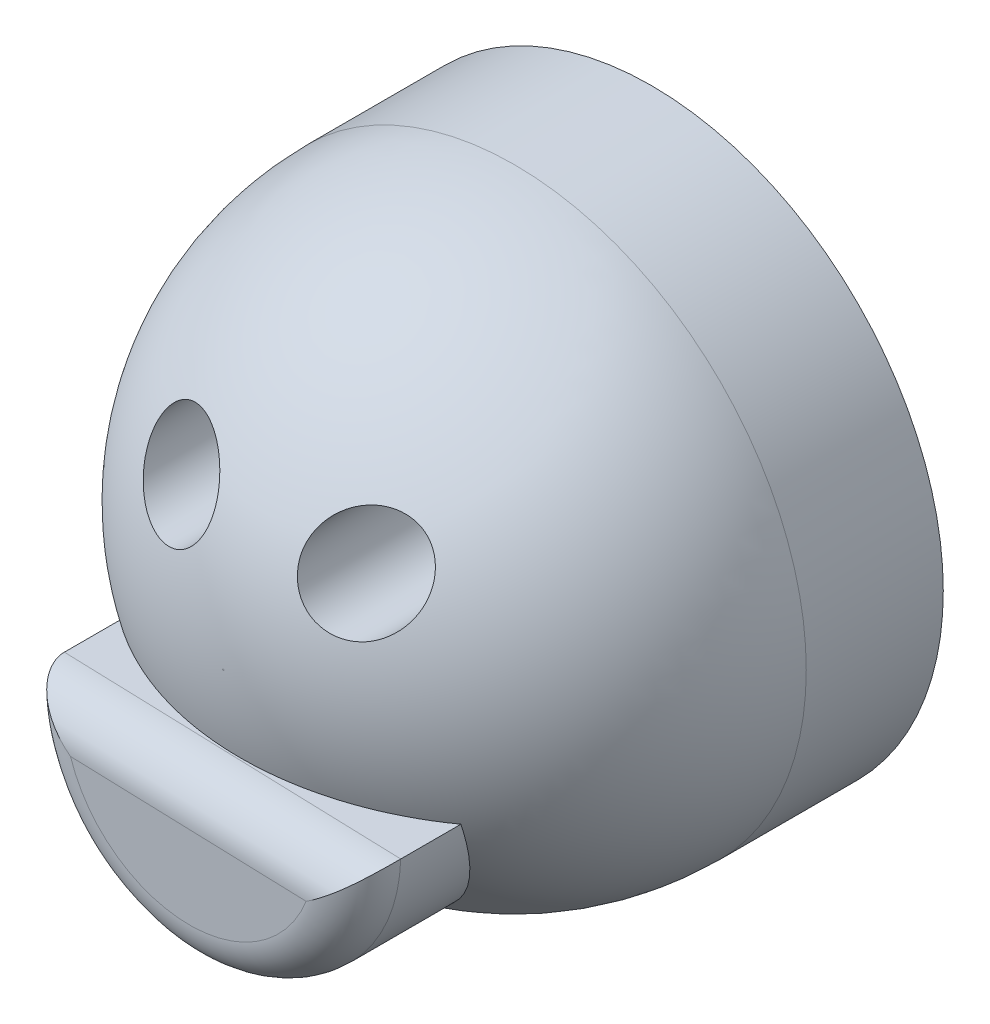
from build123d import *

# Parameters (mm, degrees)
SKETCH1_R           = 34.075
BOSS_EXTRUDE1_DEPTH = 50
FILLET1_R           = 34
SKETCH3_R           = 5.5
CUT_EXTRUDE1_DEPTH  = 57
BOSS_EXTRUDE2_DEPTH = 54
FILLET2_R           = 5
SKETCH5_R           = 28.2539
CUT_EXTRUDE2_DEPTH  = 27


with BuildPart() as part:
    # Sketch1 → Boss-Extrude1 (new body)
    with BuildSketch(Plane.XY):
        Circle(SKETCH1_R)
    extrude(amount=BOSS_EXTRUDE1_DEPTH)

    # Fillet1
    fillet1_edges = [part.edges().sort_by_distance(p)[0] for p in [
        (-34.075, 0, 50),
    ]]
    fillet(fillet1_edges, radius=FILLET1_R)

    # Sketch3 → Cut-Extrude1 (cut)
    with BuildSketch(Plane(origin=(0, 0, 0), x_dir=(-1, 0, 0), z_dir=(0, 0, -1))):
        with Locations((-11.427232, 12.850521)):
            Circle(SKETCH3_R)
        with Locations((9.257377, 12.850521)):
            Circle(SKETCH3_R)
    extrude(amount=-CUT_EXTRUDE1_DEPTH, mode=Mode.SUBTRACT)

    # Sketch4 → Boss-Extrude2 (add)
    with BuildSketch(Plane(origin=(0, 0, 0), x_dir=(-1, 0, 0), z_dir=(0, 0, -1))):
        with BuildLine():
            Line((-19.721396, -9.77574), (19.555863, -8.501695))
            ThreePointArc((19.555863, -8.501695), (0.554256, -28.777347), (-19.721396, -9.77574))
        make_face()
    extrude(amount=-BOSS_EXTRUDE2_DEPTH)

    # Fillet2
    fillet2_edges = [part.edges().sort_by_distance(p)[0] for p in [
        (-0.554256, -28.777347, 54),
        (0.082767, -9.138717, 54),
    ]]
    fillet(fillet2_edges, radius=FILLET2_R)

    # Sketch5 → Cut-Extrude2 (cut)
    with BuildSketch(Plane(origin=(0, 0, 0), x_dir=(-1, 0, 0), z_dir=(0, 0, -1))):
        Circle(SKETCH5_R)
    extrude(amount=-CUT_EXTRUDE2_DEPTH, mode=Mode.SUBTRACT)


solid = part.part
